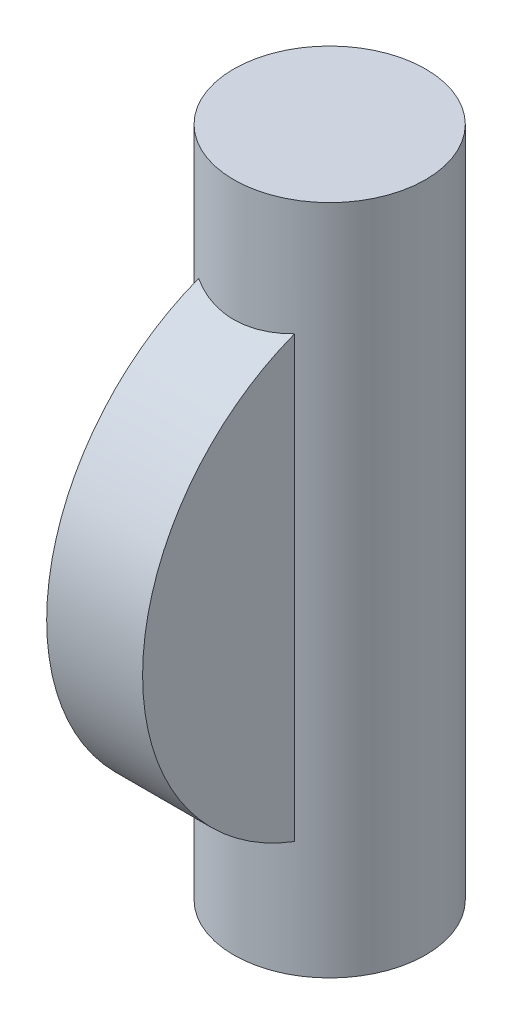
from build123d import *

# Parameters (mm, degrees)
SKETCH1_R                = 2.54
BOSS_EXTRUDE1_DEPTH      = 17.78
BOSS_EXTRUDE2_DEPTH      = 1.27
BOSS_EXTRUDE2_DEPTH_BACK = 1.27


with BuildPart() as part:
    # Sketch1 → Boss-Extrude1 (new body)
    with BuildSketch(Plane(origin=(0, 0, 0), x_dir=(1, 0, 0), z_dir=(0, 1, 0))):
        Circle(SKETCH1_R)
    extrude(amount=BOSS_EXTRUDE1_DEPTH)

    # Sketch2 → Boss-Extrude2 (add, two sides: drawn at the far end of the back side and taken through both)
    with BuildSketch(Plane(origin=(0, 0, 0), x_dir=(0, 0, -1), z_dir=(1, 0, 0)).offset(-BOSS_EXTRUDE2_DEPTH_BACK)):
        with BuildLine():
            Line((0, 2.667), (0, 15.113))
            ThreePointArc((0, 15.113), (-6.223, 8.89), (0, 2.667))
        make_face()
    extrude(amount=BOSS_EXTRUDE2_DEPTH + BOSS_EXTRUDE2_DEPTH_BACK)


solid = part.part
